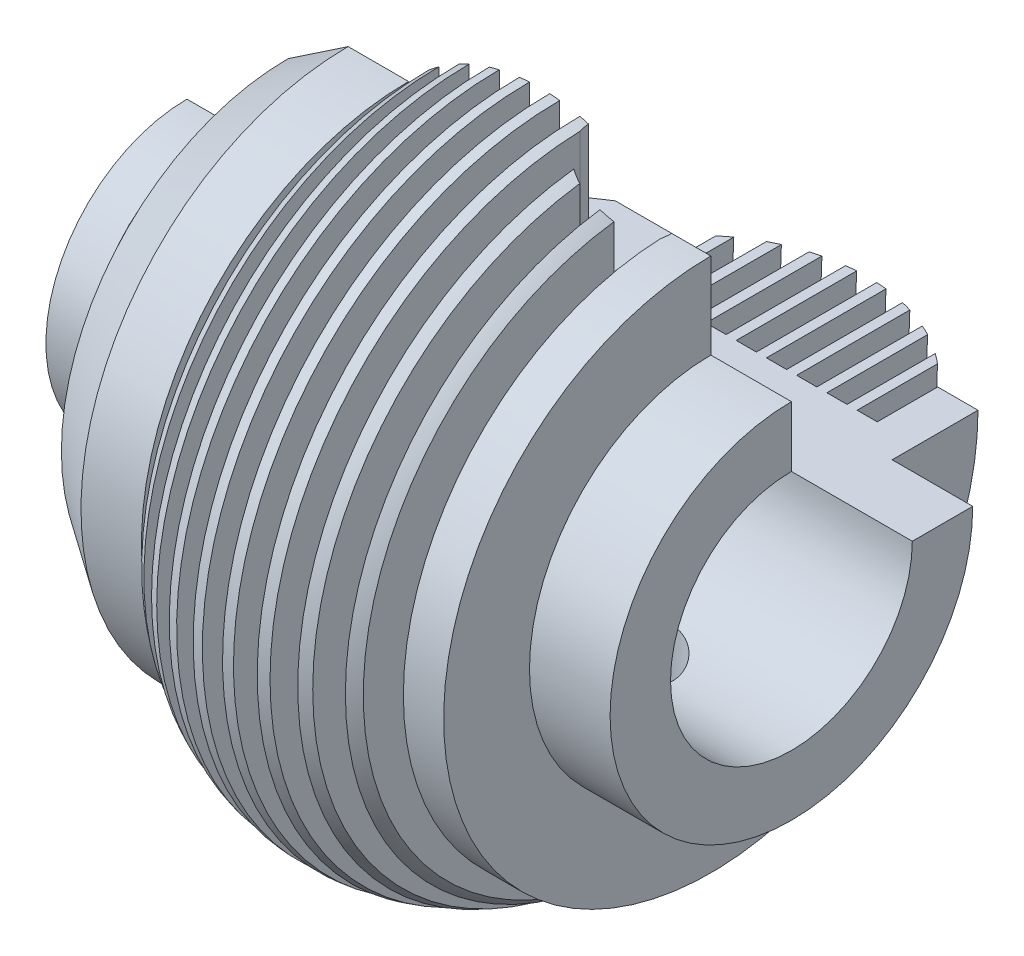
from build123d import *

# Parameters (mm, degrees)
REVOLUCI_N2_ANGLE     = 270
CROQUIS12_R           = 10.307991632
CORTAR_EXTRUIR1_DEPTH = 147.509045884
CROQUIS12_2_R         = 10.307991632
CORTAR_EXTRUIR2_DEPTH = 147.509045935


with BuildPart() as part:
    # Croquis2 → Revolución2 (revolve)
    with BuildSketch(Plane.XY):
        with BuildLine():
            Line((-25, 0), (-25, 15))
            Line((-25, 15), (75, 15))
            Line((75, 15), (75, 30))
            Line((75, 30), (55, 30))
            Line((55, 30), (55, 51.3))
            Line((55, 51.3), (45, 51.3))
            Line((45, 51.3), (45, 36.3))
            Line((45, 36.3), (40, 36.3))
            Line((40, 36.3), (40, 56.246772292))
            ThreePointArc((40, 56.246772292), (38.76797888, 57.241607231), (37.5, 58.19018625))
            Line((37.5, 58.19018625), (37.5, 36.3))
            Line((37.5, 36.3), (32.5, 36.3))
            Line((32.5, 36.3), (32.5, 61.290245221))
            ThreePointArc((32.5, 61.290245221), (31.259906067, 61.920128903), (30, 62.509385314))
            Line((30, 62.509385314), (30, 36.3))
            Line((30, 36.3), (25, 36.3))
            Line((25, 36.3), (25, 64.384554711))
            ThreePointArc((25, 64.384554711), (23.755157932, 64.744183719), (22.5, 65.065965261))
            Line((22.5, 65.065965261), (22.5, 36.3))
            Line((22.5, 36.3), (17.5, 36.3))
            Line((17.5, 36.3), (17.5, 65.957524099))
            ThreePointArc((17.5, 65.957524099), (16.251612737, 66.085843567), (15, 66.177507085))
            Line((15, 66.177507085), (15, 36.3))
            Line((15, 36.3), (10, 36.3))
            Line((10, 36.3), (10, 66.177507085))
            ThreePointArc((10, 66.177507085), (8.748387263, 66.085843567), (7.5, 65.957524099))
            Line((7.5, 65.957524099), (7.5, 36.3))
            Line((7.5, 36.3), (2.5, 36.3))
            Line((2.5, 36.3), (2.5, 65.065965261))
            ThreePointArc((2.5, 65.065965261), (1.244842068, 64.744183719), (0, 64.384554711))
            Line((0, 64.384554711), (0, 36.3))
            Line((0, 36.3), (-5, 36.3))
            Line((-5, 36.3), (-5, 62.509385314))
            ThreePointArc((-5, 62.509385314), (-6.259906067, 61.920128903), (-7.5, 61.290245221))
            Line((-7.5, 61.290245221), (-7.5, 36.3))
            Line((-7.5, 36.3), (-12.5, 36.3))
            Line((-12.5, 36.3), (-12.5, 58.19018625))
            ThreePointArc((-12.5, 58.19018625), (-13.76797888, 57.241607231), (-15, 56.246772292))
            Line((-15, 56.246772292), (-15, 36.3))
            Line((-15, 36.3), (-20, 36.3))
            Line((-20, 36.3), (-20, 51.3))
            Line((-20, 51.3), (-35, 51.3))
            Line((-35, 51.3), (-49.922676306, 41.234527738))
            Line((-49.922676306, 41.234527738), (-49.922676306, 20))
            ThreePointArc((-49.922676306, 20), (-52.851608494, 12.928932188), (-59.922676306, 10))
            Line((-59.922676306, 10), (-65, 10))
            Line((-65, 10), (-65, 20))
            Line((-65, 20), (-75, 20))
            Line((-75, 20), (-75, 0))
            Line((-75, 0), (-25, 0))
        make_face()
    revolve(axis=Axis((-75, -15, 0), (1, 0, 0)), revolution_arc=REVOLUCI_N2_ANGLE)

    # Croquis12 → Cortar-Extruir1 (cut, through all)
    with BuildSketch(Plane(origin=(0, 0, 0), x_dir=(1, 0, 0), z_dir=(0, 1, 0))):
        with Locations((35, 0)):
            Circle(CROQUIS12_R)
    extrude(amount=CORTAR_EXTRUIR1_DEPTH, mode=Mode.SUBTRACT)

    # Croquis12_2 → Cortar-Extruir2 (cut, through all)
    with BuildSketch(Plane(origin=(0, 0, 0), x_dir=(1, 0, 0), z_dir=(0, 1, 0))):
        with Locations((35, 0)):
            Circle(CROQUIS12_2_R)
    extrude(amount=-CORTAR_EXTRUIR2_DEPTH, mode=Mode.SUBTRACT)


solid = part.part
